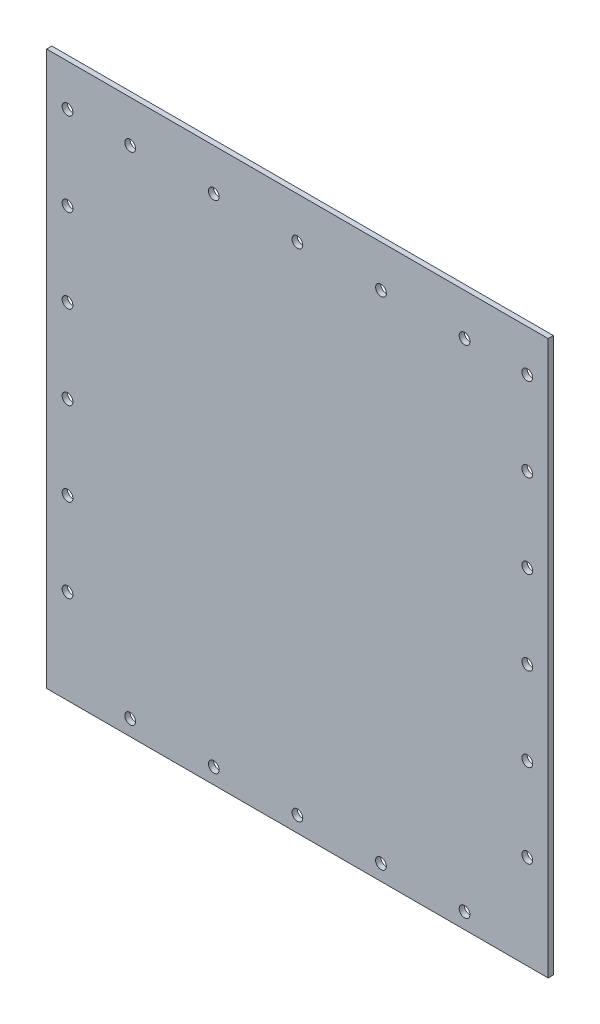
from build123d import *

# Parameters (mm, degrees)
SKETCH1_W           = 152.4
SKETCH1_H           = 168.2716
SKETCH1_R           = 1.63195
BOSS_EXTRUDE1_DEPTH = 1.5875


with BuildPart() as part:
    # Sketch1 → Boss-Extrude1 (new body)
    with BuildSketch(Plane.XY):
        with Locations((76.2, -185.7358)):
            Rectangle(SKETCH1_W, SKETCH1_H)
        with Locations((6.35, -241.3)):
            Circle(SKETCH1_R, mode=Mode.SUBTRACT)
        with Locations((25.4, -265.1125)):
            Circle(SKETCH1_R, mode=Mode.SUBTRACT)
        with Locations((6.35, -215.9)):
            Circle(SKETCH1_R, mode=Mode.SUBTRACT)
        with Locations((50.8, -265.1125)):
            Circle(SKETCH1_R, mode=Mode.SUBTRACT)
        with Locations((76.2, -265.1125)):
            Circle(SKETCH1_R, mode=Mode.SUBTRACT)
        with Locations((6.35, -190.5)):
            Circle(SKETCH1_R, mode=Mode.SUBTRACT)
        with Locations((6.35, -165.1)):
            Circle(SKETCH1_R, mode=Mode.SUBTRACT)
        with Locations((6.35, -139.7)):
            Circle(SKETCH1_R, mode=Mode.SUBTRACT)
        with Locations((101.6, -265.1125)):
            Circle(SKETCH1_R, mode=Mode.SUBTRACT)
        with Locations((127, -265.1125)):
            Circle(SKETCH1_R, mode=Mode.SUBTRACT)
        with Locations((146.05, -241.3)):
            Circle(SKETCH1_R, mode=Mode.SUBTRACT)
        with Locations((146.05, -215.9)):
            Circle(SKETCH1_R, mode=Mode.SUBTRACT)
        with Locations((146.05, -190.5)):
            Circle(SKETCH1_R, mode=Mode.SUBTRACT)
        with Locations((146.05, -165.1)):
            Circle(SKETCH1_R, mode=Mode.SUBTRACT)
        with Locations((146.05, -139.7)):
            Circle(SKETCH1_R, mode=Mode.SUBTRACT)
        with Locations((6.35, -114.3)):
            Circle(SKETCH1_R, mode=Mode.SUBTRACT)
        with Locations((25.4, -114.3)):
            Circle(SKETCH1_R, mode=Mode.SUBTRACT)
        with Locations((50.8, -114.3)):
            Circle(SKETCH1_R, mode=Mode.SUBTRACT)
        with Locations((76.2, -114.3)):
            Circle(SKETCH1_R, mode=Mode.SUBTRACT)
        with Locations((101.6, -114.3)):
            Circle(SKETCH1_R, mode=Mode.SUBTRACT)
        with Locations((127, -114.3)):
            Circle(SKETCH1_R, mode=Mode.SUBTRACT)
        with Locations((146.05, -114.3)):
            Circle(SKETCH1_R, mode=Mode.SUBTRACT)
    extrude(amount=BOSS_EXTRUDE1_DEPTH)


solid = part.part
